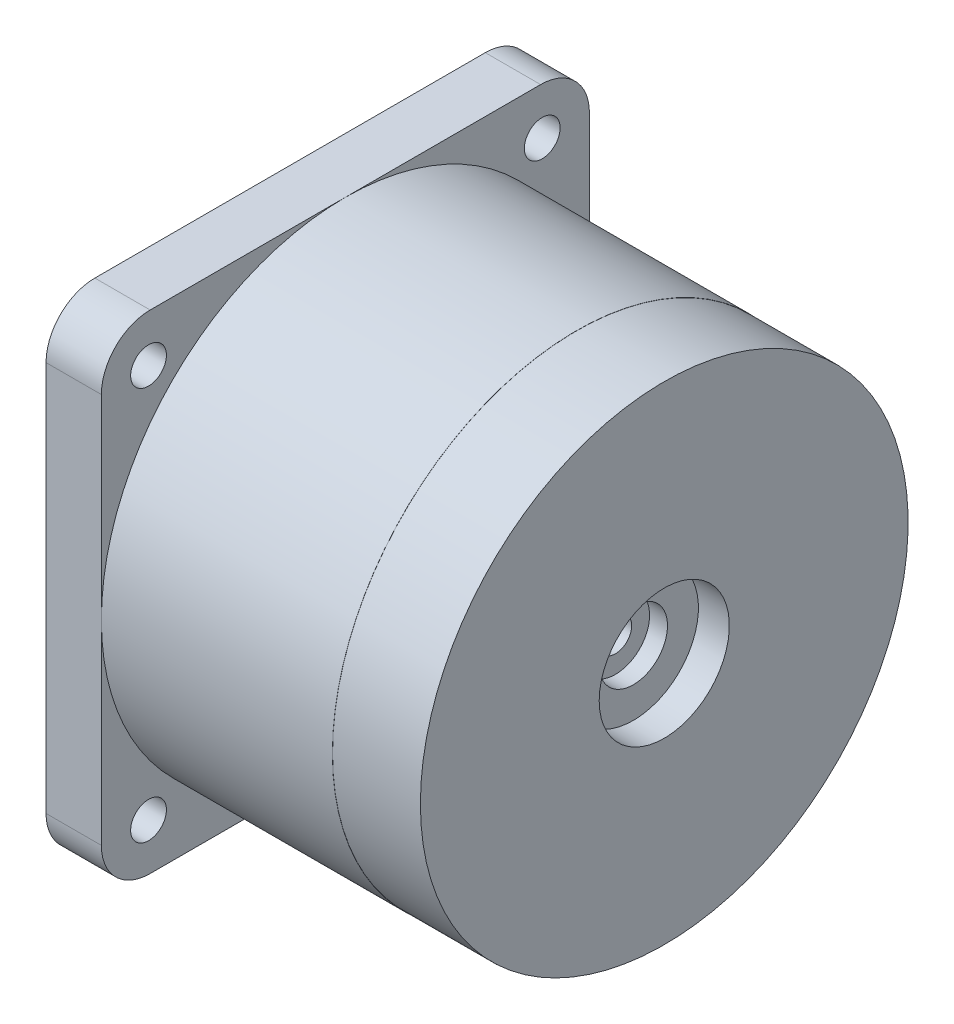
from build123d import *

# Parameters (mm, degrees)
ESQUISSE2_W             = 30
ESQUISSE2_H             = 30
ESQUISSE2_R             = 1.1
EXTRUSION1_DEPTH        = 3.4
ESQUISSE3_R             = 13.5
ENL_V_MAT_EXTRU_1_DEPTH = 1.6
CONG_1_R                = 3
ESQUISSE4_R             = 5
EXTRUSION2_DEPTH        = 7.55


with BuildPart() as part:
    # Esquisse1 → Révolution1 (revolve)
    with BuildSketch(Plane.XY, mode=Mode.PRIVATE) as r_volution1_sk:
        Polygon((0, 0), (0, 14.99), (-5.4, 14.99), (-5.4, 15), (-19.6, 15), (-19.6, 0), align=None)
    revolve(r_volution1_sk.sketch.rotate(Axis((0, 0, 0), (1, 0, 0)), 90), axis=Axis((0, 0, 0), (1, 0, 0)))  # turned: the seam where the file's is

    # Esquisse2 → Extrusion1 (add)
    with BuildSketch(Plane.ZY.offset(19.6)):
        Rectangle(ESQUISSE2_W, ESQUISSE2_H)
        with Locations((-12.1, 12.1)):
            Circle(ESQUISSE2_R, mode=Mode.SUBTRACT)
        with Locations((12.1, 12.1)):
            Circle(ESQUISSE2_R, mode=Mode.SUBTRACT)
        with Locations((-12.1, -12.1)):
            Circle(ESQUISSE2_R, mode=Mode.SUBTRACT)
        with Locations((12.1, -12.1)):
            Circle(ESQUISSE2_R, mode=Mode.SUBTRACT)
    extrude(amount=EXTRUSION1_DEPTH)

    # Esquisse3 → Enlèv. mat.-Extru.1 (cut)
    with BuildSketch(Plane.ZY.offset(23)):
        Circle(ESQUISSE3_R)
    extrude(amount=-ENL_V_MAT_EXTRU_1_DEPTH, mode=Mode.SUBTRACT)

    # Congé1
    cong_1_edges = [part.edges().sort_by_distance(p)[0] for p in [
        (-21.3, 15, -15),
        (-21.3, -15, -15),
        (-21.3, -15, 15),
        (-21.3, 15, 15),
    ]]
    fillet(cong_1_edges, radius=CONG_1_R)

    # Esquisse4 → Extrusion2 (add)
    with BuildSketch(Plane.ZY.offset(21.4)):
        with Locations((0, -4.9)):
            Circle(ESQUISSE4_R)
    extrude(amount=EXTRUSION2_DEPTH)

    # Esquisse5 → Enlèvement de matière-Révolution1 (revolve, cut)
    with BuildSketch(Plane.XY, mode=Mode.PRIVATE) as enl_vement_de_mati_re_r_volution1_sk:
        Polygon((0, 0), (0, 4), (-1.9, 4), (-1.9, 2.1), (-3, 2.1), (-3, 1), (-11.5, 1), (-11.5, 0), align=None)
    revolve(enl_vement_de_mati_re_r_volution1_sk.sketch.rotate(Axis((0, 0, 0), (1, 0, 0)), 90), axis=Axis((0, 0, 0), (1, 0, 0)), mode=Mode.SUBTRACT)  # turned: the seam where the file's is


solid = part.part
